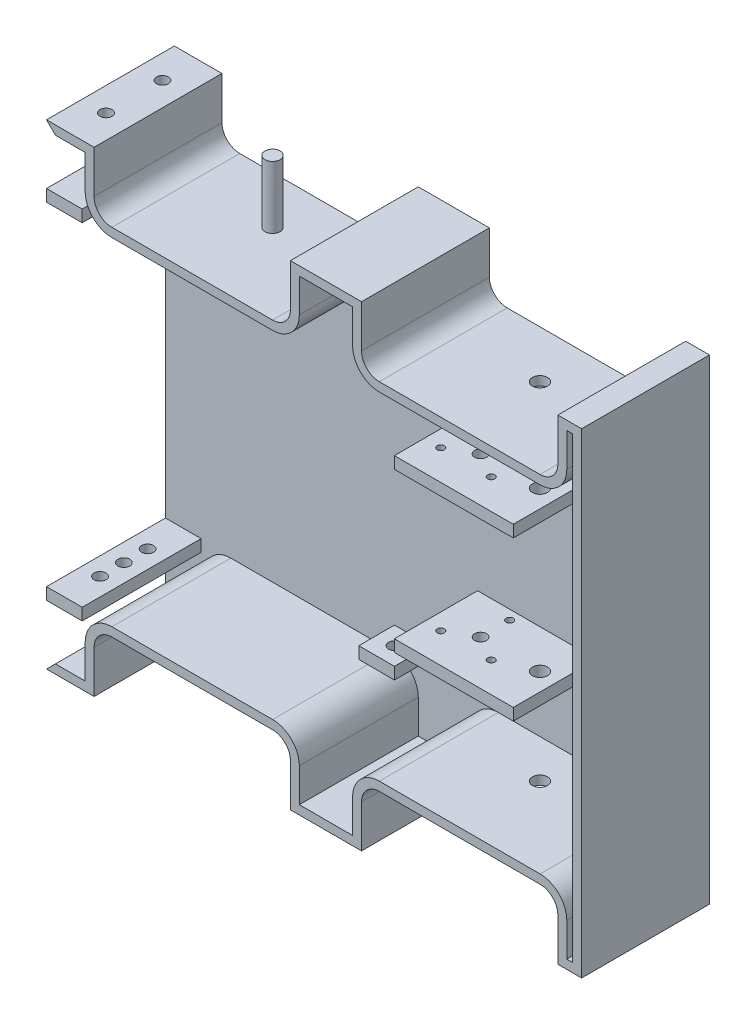
from build123d import *

# Parameters (mm, degrees)
BOSS_EXTRUDE1_DEPTH = 7.5
BOSS_EXTRUDE3_DEPTH = 100
SKETCH5_R           = 6.35
CUT_EXTRUDE1_DEPTH  = 335
SKETCH6_W           = 100
SKETCH6_H           = 10
BOSS_EXTRUDE4_DEPTH = 70
SKETCH7_R           = 6.35
CUT_EXTRUDE2_DEPTH  = 322
SKETCH9_R           = 3
SKETCH9_R_2         = 5
CUT_EXTRUDE3_DEPTH  = 53
SKETCH10_R          = 6.35
BOSS_EXTRUDE5_DEPTH = 60
SKETCH11_R          = 5
CUT_EXTRUDE4_DEPTH  = 490
SKETCH12_W          = 30
SKETCH12_H          = 10
BOSS_EXTRUDE6_DEPTH = 30
SKETCH13_R          = 5
CUT_EXTRUDE5_DEPTH  = 10
SKETCH14_W          = 30
SKETCH14_H          = 10
BOSS_EXTRUDE7_DEPTH = 100
SKETCH15_R          = 5
CUT_EXTRUDE6_DEPTH  = 35


with BuildPart() as part:
    # Sketch2 → Boss-Extrude1 (new body)
    with BuildSketch(Plane.XY):
        with BuildLine():
            Line((-19.9, 200), (39.9, 200))
            Line((39.9, 200), (39.9, 164.2))
            ThreePointArc((39.9, 164.2), (44.293398282, 153.593398282), (54.9, 149.2))
            Line((54.9, 149.2), (190, 149.2))
            ThreePointArc((190, 149.2), (200.606601718, 153.593398282), (205, 164.2))
            Line((205, 164.2), (205, 200))
            Line((205, 200), (225, 200))
            Line((225, 200), (225, -200))
            Line((225, -200), (205, -200))
            Line((205, -200), (205, -164.2))
            ThreePointArc((205, -164.2), (200.606601718, -153.593398282), (190, -149.2))
            Line((190, -149.2), (54.9, -149.2))
            ThreePointArc((54.9, -149.2), (44.293398282, -153.593398282), (39.9, -164.2))
            Line((39.9, -164.2), (39.9, -200))
            Line((39.9, -200), (-19.9, -200))
            Line((-19.9, -200), (-19.9, -164.2))
            ThreePointArc((-19.9, -164.2), (-24.293398282, -153.593398282), (-34.9, -149.2))
            Line((-34.9, -149.2), (-170, -149.2))
            ThreePointArc((-170, -149.2), (-180.606601718, -153.593398282), (-185, -164.2))
            Line((-185, -164.2), (-185, -200))
            Line((-185, -200), (-225, -200))
            Line((-225, -200), (-225, 200))
            Line((-225, 200), (-185, 200))
            Line((-185, 200), (-185, 164.2))
            ThreePointArc((-185, 164.2), (-180.606601718, 153.593398282), (-170, 149.2))
            Line((-170, 149.2), (-34.9, 149.2))
            ThreePointArc((-34.9, 149.2), (-24.293398282, 153.593398282), (-19.9, 164.2))
            Line((-19.9, 164.2), (-19.9, 200))
        make_face()
    extrude(amount=BOSS_EXTRUDE1_DEPTH)

    # Sketch4 → Boss-Extrude3 (add)
    with BuildSketch(Plane.XY.offset(7.5)):
        with BuildLine():
            Line((-217.5, 192.5), (-225, 200))
            Line((-225, 200), (-185, 200))
            Line((-185, 200), (-185, 164.2))
            ThreePointArc((-185, 164.2), (-180.606601718, 153.593398282), (-170, 149.2))
            Line((-170, 149.2), (-34.9, 149.2))
            ThreePointArc((-34.9, 149.2), (-24.293398282, 153.593398282), (-19.9, 164.2))
            Line((-19.9, 164.2), (-19.9, 200))
            Line((-19.9, 200), (39.9, 200))
            Line((39.9, 200), (39.9, 164.2))
            ThreePointArc((39.9, 164.2), (44.293398282, 153.593398282), (54.9, 149.2))
            Line((54.9, 149.2), (190, 149.2))
            ThreePointArc((190, 149.2), (200.606601718, 153.593398282), (205, 164.2))
            Line((205, 164.2), (205, 200))
            Line((205, 200), (225, 200))
            Line((225, 200), (225, -200))
            Line((225, -200), (205, -200))
            Line((205, -200), (205, -164.2))
            ThreePointArc((205, -164.2), (200.606601718, -153.593398282), (190, -149.2))
            Line((190, -149.2), (54.9, -149.2))
            ThreePointArc((54.9, -149.2), (44.293398282, -153.593398282), (39.9, -164.2))
            Line((39.9, -164.2), (39.9, -200))
            Line((39.9, -200), (-19.9, -200))
            Line((-19.9, -200), (-19.9, -164.2))
            ThreePointArc((-19.9, -164.2), (-24.293398282, -153.593398282), (-34.9, -149.2))
            Line((-34.9, -149.2), (-170, -149.2))
            ThreePointArc((-170, -149.2), (-180.606601718, -153.593398282), (-185, -164.2))
            Line((-185, -164.2), (-185, -200))
            Line((-185, -200), (-225, -200))
            Line((-225, -200), (-217.5, -192.5))
            Line((-217.5, -192.5), (-192.5, -192.5))
            Line((-192.5, -192.5), (-192.5, -164.2))
            ThreePointArc((-192.5, -164.2), (-185.909902577, -148.290097423), (-170, -141.7))
            Line((-170, -141.7), (-34.9, -141.7))
            ThreePointArc((-34.9, -141.7), (-18.990097423, -148.290097423), (-12.4, -164.2))
            Line((-12.4, -164.2), (-12.4, -192.5))
            Line((-12.4, -192.5), (32.4, -192.5))
            Line((32.4, -192.5), (32.4, -164.2))
            ThreePointArc((32.4, -164.2), (38.990097423, -148.290097423), (54.9, -141.7))
            Line((54.9, -141.7), (190, -141.7))
            ThreePointArc((190, -141.7), (205.909902577, -148.290097423), (212.5, -164.2))
            Line((212.5, -164.2), (212.5, -192.5))
            Line((212.5, -192.5), (217.5, -192.5))
            Line((217.5, -192.5), (217.5, 192.5))
            Line((217.5, 192.5), (212.5, 192.5))
            Line((212.5, 192.5), (212.5, 164.2))
            ThreePointArc((212.5, 164.2), (205.909902577, 148.290097423), (190, 141.7))
            Line((190, 141.7), (54.9, 141.7))
            ThreePointArc((54.9, 141.7), (38.990097423, 148.290097423), (32.4, 164.2))
            Line((32.4, 164.2), (32.4, 192.5))
            Line((32.4, 192.5), (-12.4, 192.5))
            Line((-12.4, 192.5), (-12.4, 164.2))
            ThreePointArc((-12.4, 164.2), (-18.990097423, 148.290097423), (-34.9, 141.7))
            Line((-34.9, 141.7), (-170, 141.7))
            ThreePointArc((-170, 141.7), (-185.909902577, 148.290097423), (-192.5, 164.2))
            Line((-192.5, 164.2), (-192.5, 192.5))
            Line((-192.5, 192.5), (-217.5, 192.5))
        make_face()
    extrude(amount=BOSS_EXTRUDE3_DEPTH)

    # Sketch5 → Cut-Extrude1 (cut)
    with BuildSketch(Plane.XZ.offset(149.2)):
        with Locations((-102.45, 40)):
            Circle(SKETCH5_R)
        with Locations((122.45, 40)):
            Circle(SKETCH5_R)
    extrude(amount=-CUT_EXTRUDE1_DEPTH, mode=Mode.SUBTRACT)

    # Sketch6 → Boss-Extrude4 (add)
    with BuildSketch(Plane.XY.offset(7.5)):
        with Locations((87.5, 66.7)):
            Rectangle(SKETCH6_W, SKETCH6_H)
        with Locations((87.5, -66.7)):
            Rectangle(SKETCH6_W, SKETCH6_H)
    extrude(amount=BOSS_EXTRUDE4_DEPTH)

    # Sketch7 → Cut-Extrude2 (cut)
    with BuildSketch(Plane.XZ.offset(149.2)):
        with Locations((122.45, 40)):
            Circle(SKETCH7_R)
    extrude(amount=-CUT_EXTRUDE2_DEPTH, mode=Mode.SUBTRACT)

    # Sketch9 → Cut-Extrude3 (cut)
    with BuildSketch(Plane.XZ.offset(-61.7)):
        with Locations((72.5, 15.5)):
            Circle(SKETCH9_R)
        with Locations((51.282377607, 52.25)):
            Circle(SKETCH9_R)
        with Locations((93.717622393, 52.25)):
            Circle(SKETCH9_R)
        with Locations((72.5, 40)):
            Circle(SKETCH9_R_2)
    cut_extrude3 = extrude(amount=-CUT_EXTRUDE3_DEPTH, mode=Mode.SUBTRACT)

    # Mirror1: Cut-Extrude3 across plane
    add(cut_extrude3.mirror(Plane.ZX), mode=Mode.SUBTRACT)

    # Sketch10 → Boss-Extrude5 (add)
    with BuildSketch(Plane(origin=(0, -141.7, 0), x_dir=(1, 0, 0), z_dir=(0, 1, 0))):
        with Locations((-102.45, -40)):
            Circle(SKETCH10_R)
    boss_extrude5 = extrude(amount=-BOSS_EXTRUDE5_DEPTH)

    # Mirror2: Boss-Extrude5 across plane
    add(boss_extrude5.mirror(Plane.ZX))

    # Sketch11 → Cut-Extrude4 (cut)
    with BuildSketch(Plane.XZ.offset(200)):
        with Locations((-205, 77.5)):
            Circle(SKETCH11_R)
        with Locations((-205, 30)):
            Circle(SKETCH11_R)
    extrude(amount=-CUT_EXTRUDE4_DEPTH, mode=Mode.SUBTRACT)

    # Sketch12 → Boss-Extrude6 (add)
    with BuildSketch(Plane.XY.offset(7.5)):
        with Locations((-17.4, 126.7)):
            Rectangle(SKETCH12_W, SKETCH12_H)
    boss_extrude6 = extrude(amount=BOSS_EXTRUDE6_DEPTH)

    # Sketch13 → Cut-Extrude5 (cut)
    with BuildSketch(Plane.XZ.offset(-121.7)):
        with Locations((-17.4, 22.5)):
            Circle(SKETCH13_R)
    cut_extrude5 = extrude(amount=-CUT_EXTRUDE5_DEPTH, mode=Mode.SUBTRACT)

    # Mirror3: Boss-Extrude6, Cut-Extrude5 across plane
    add(boss_extrude6.mirror(Plane.ZX))
    add(cut_extrude5.mirror(Plane.ZX), mode=Mode.SUBTRACT)

    # Sketch14 → Boss-Extrude7 (add)
    with BuildSketch(Plane.XY.offset(7.5)):
        with Locations((-210, 145)):
            Rectangle(SKETCH14_W, SKETCH14_H)
    boss_extrude7 = extrude(amount=BOSS_EXTRUDE7_DEPTH)

    # Sketch15 → Cut-Extrude6 (cut)
    with BuildSketch(Plane.XZ.offset(-140)):
        with Locations((-210, 77.5)):
            Circle(SKETCH15_R)
        with Locations((-210, 57.5)):
            Circle(SKETCH15_R)
        with Locations((-210, 37.5)):
            Circle(SKETCH15_R)
    cut_extrude6 = extrude(amount=-CUT_EXTRUDE6_DEPTH, mode=Mode.SUBTRACT)

    # Mirror4: Boss-Extrude7, Cut-Extrude6 across plane
    add(boss_extrude7.mirror(Plane.ZX))
    add(cut_extrude6.mirror(Plane.ZX), mode=Mode.SUBTRACT)


solid = part.part
